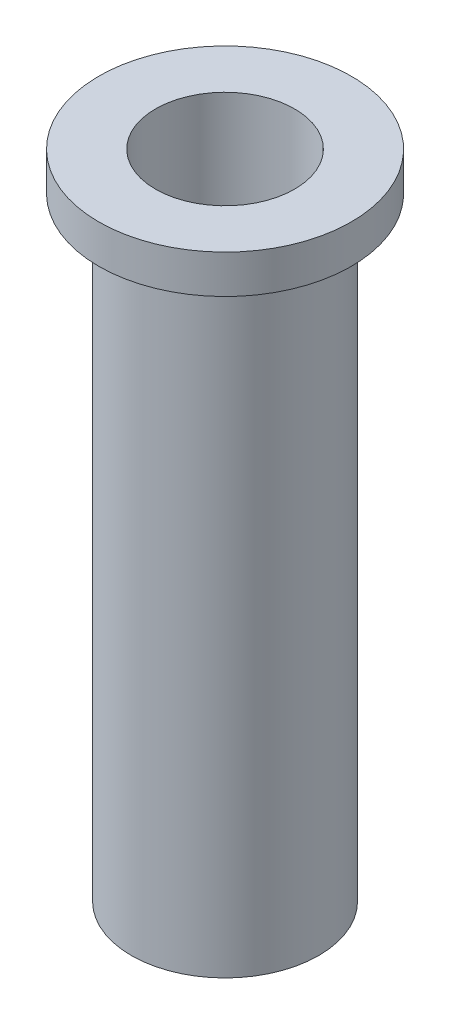
from build123d import *

# Parameters (mm, degrees)
SKETCH1_R           = 7.3025
BOSS_EXTRUDE1_DEPTH = 50.8
SKETCH2_R           = 1.6129
CUT_EXTRUDE1_DEPTH  = 50.8
SKETCH5_W           = 2.54
SKETCH5_H           = 3
SKETCH6_R           = 5.4229
CUT_EXTRUDE3_DEPTH  = 35.68192


with BuildPart() as part:
    # Sketch1 → Boss-Extrude1 (new body)
    with BuildSketch(Plane(origin=(0, 0, 0), x_dir=(1, 0, 0), z_dir=(0, 1, 0))):
        Circle(SKETCH1_R)
    extrude(amount=BOSS_EXTRUDE1_DEPTH)

    # Sketch2 → Cut-Extrude1 (cut)
    with BuildSketch(Plane(origin=(0, 50.8, 0), x_dir=(1, 0, 0), z_dir=(0, 1, 0))):
        Circle(SKETCH2_R)
    extrude(amount=-CUT_EXTRUDE1_DEPTH, mode=Mode.SUBTRACT)

    # Sketch3 → Cut-Revolve1 (revolve, cut)
    with BuildSketch(Plane.XY):
        Polygon((-5.4229, 15.118959148), (-1.6129, 9.215668113), (-1.6129, 15.118959148), align=None)
    revolve(axis=Axis((0, 34.671, 0), (0, -1, 0)), mode=Mode.SUBTRACT)

    # Sketch5 → Revolve1 (revolve)
    with BuildSketch(Plane(origin=(0, 0, 0), x_dir=(0, 0, -1), z_dir=(1, 0, 0))):
        with Locations((8.5725, 49.3)):
            Rectangle(SKETCH5_W, SKETCH5_H)
    revolve(axis=Axis((0, 34.671, 0), (0, -1, 0)))

    # Sketch6 → Cut-Extrude3 (cut)
    with BuildSketch(Plane(origin=(0, 50.8, 0), x_dir=(1, 0, 0), z_dir=(0, 1, 0))):
        Circle(SKETCH6_R)
    extrude(amount=-CUT_EXTRUDE3_DEPTH, mode=Mode.SUBTRACT)


solid = part.part
